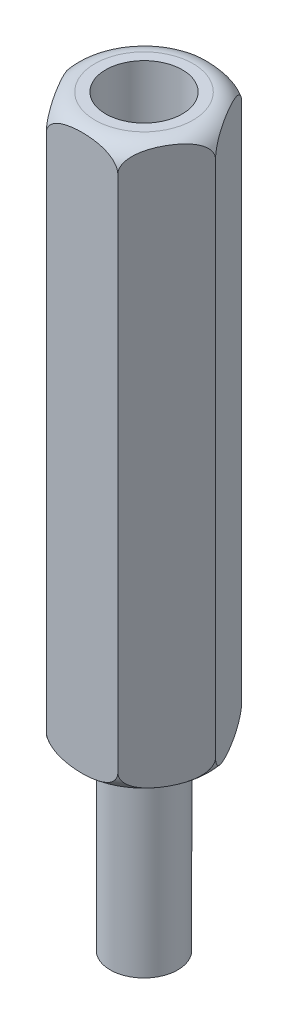
from build123d import *

# Parameters (mm, degrees)
BOSS_EXTRUDE1_DEPTH      = 25
M3_CLEARANCE_HOLE1_D     = 3.4
M3_CLEARANCE_HOLE1_DEPTH = 12
M3_CLEARANCE_HOLE1_TIP   = 1.021463052
SKETCH5_R                = 1.5
BOSS_EXTRUDE2_DEPTH      = 8


with BuildPart() as part:
    # Sketch1 → Boss-Extrude1 (new body)
    with BuildSketch(Plane(origin=(0, 0, 0), x_dir=(1, 0, 0), z_dir=(0, 1, 0))):
        Polygon((3.175426481, 0), (1.58771324, 2.75), (-1.58771324, 2.75), (-3.175426481, 0), (-1.58771324, -2.75), (1.58771324, -2.75), align=None)
    extrude(amount=BOSS_EXTRUDE1_DEPTH)

    # M3 Clearance Hole1
    with Locations(Plane(origin=(0, 25, 0), x_dir=(-1, 0, 0), z_dir=(0, 1, 0))):
        with Locations((0, 0)):
            Hole(M3_CLEARANCE_HOLE1_D / 2, depth=M3_CLEARANCE_HOLE1_DEPTH)
            with Locations((0, 0, -(M3_CLEARANCE_HOLE1_DEPTH + M3_CLEARANCE_HOLE1_TIP / 2))):  # 118° drill point
                Cone(0, M3_CLEARANCE_HOLE1_D / 2, M3_CLEARANCE_HOLE1_TIP, mode=Mode.SUBTRACT)

    # Sketch4 → Cut-Revolve1 (revolve, cut)
    with BuildSketch(Plane.XY):
        with BuildLine():
            Line((-2.175426481, 25), (-3.175426481, 25))
            Line((-3.175426481, 25), (-3.175426481, 24))
            ThreePointArc((-3.175426481, 24), (-2.882533262, 24.707106781), (-2.175426481, 25))
        make_face()
        with BuildLine():
            Line((-3.175426481, 1), (-3.175426481, 0))
            Line((-3.175426481, 0), (-2.175426481, 0))
            ThreePointArc((-2.175426481, 0), (-2.882533262, 0.292893219), (-3.175426481, 1))
        make_face()
    revolve(axis=Axis((0, 25, 0), (0, -1, 0)), mode=Mode.SUBTRACT)

    # Sketch5 → Boss-Extrude2 (add)
    with BuildSketch(Plane.XZ):
        Circle(SKETCH5_R)
    extrude(amount=BOSS_EXTRUDE2_DEPTH)


solid = part.part
